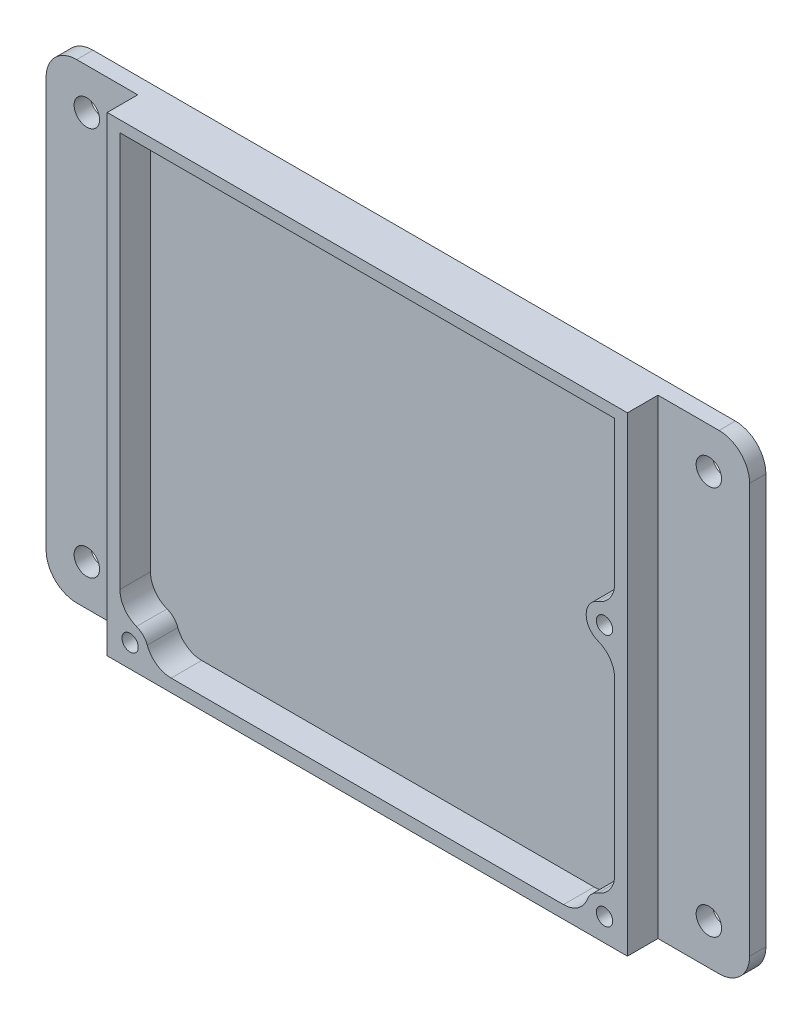
from build123d import *

# Parameters (mm, degrees)
SKETCH1_W           = 102.2
SKETCH1_H           = 92.45
SKETCH1_R           = 1.6
BOSS_EXTRUDE1_DEPTH = 6
SKETCH2_W           = 138.2
SKETCH2_H           = 92.45
SKETCH2_R           = 2.5
BOSS_EXTRUDE2_DEPTH = 3.2
FILLET1_R           = 6
FILLET2_R           = 5
FILLET3_R           = 5


with BuildPart() as part:
    # Sketch1 → Boss-Extrude1 (new body)
    with BuildSketch(Plane.XY):
        with Locations((51.1, 46.225)):
            Rectangle(SKETCH1_W, SKETCH1_H)
        with BuildLine():
            Line((94.706674091, 2.5), (7.493325909, 2.5))
            ThreePointArc((7.493325909, 2.5), (7.045584412, 7.045584412), (2.5, 7.493325909))
            Line((2.5, 7.493325909), (2.5, 90.25))
            Line((2.5, 90.25), (99.7, 90.25))
            Line((99.7, 90.25), (99.7, 57.093325909))
            ThreePointArc((99.7, 57.093325909), (94.1, 54.1), (99.7, 51.106674091))
            Line((99.7, 51.106674091), (99.7, 7.493325909))
            ThreePointArc((99.7, 7.493325909), (95.154415588, 7.045584412), (94.706674091, 2.5))
        make_face(mode=Mode.SUBTRACT)
        with Locations((4.5, 4.5)):
            Circle(SKETCH1_R, mode=Mode.SUBTRACT)
        with Locations((97.7, 4.5)):
            Circle(SKETCH1_R, mode=Mode.SUBTRACT)
        with Locations((97.7, 54.1)):
            Circle(SKETCH1_R, mode=Mode.SUBTRACT)
    extrude(amount=BOSS_EXTRUDE1_DEPTH)

    # Sketch2 → Boss-Extrude2 (add)
    with BuildSketch(Plane(origin=(0, 0, 0), x_dir=(-1, 0, 0), z_dir=(0, 0, -1))):
        with Locations((-51.1, 46.225)):
            Rectangle(SKETCH2_W, SKETCH2_H)
        with Locations((-112.2, 84.45)):
            Circle(SKETCH2_R, mode=Mode.SUBTRACT)
        with Locations((-112.2, 8)):
            Circle(SKETCH2_R, mode=Mode.SUBTRACT)
        with Locations((10, 8)):
            Circle(SKETCH2_R, mode=Mode.SUBTRACT)
        with Locations((10, 84.45)):
            Circle(SKETCH2_R, mode=Mode.SUBTRACT)
    extrude(amount=BOSS_EXTRUDE2_DEPTH)

    # Fillet1
    fillet1_edges = [part.edges().sort_by_distance(p)[0] for p in [
        (120.2, 92.45, -1.6),
        (120.2, 0, -1.6),
        (-18, 0, -1.6),
        (-18, 92.45, -1.6),
    ]]
    fillet(fillet1_edges, radius=FILLET1_R)

    # Fillet2
    fillet2_edges = [part.edges().sort_by_distance(p)[0] for p in [
        (99.7, 51.106674091, 3),
        (99.7, 57.093325909, 3),
    ]]
    fillet(fillet2_edges, radius=FILLET2_R)

    # Fillet3
    fillet3_edges = [part.edges().sort_by_distance(p)[0] for p in [
        (7.493325909, 2.5, 3),
        (94.706674091, 2.5, 3),
        (99.7, 7.493325909, 3),
        (2.5, 7.493325909, 3),
    ]]
    fillet(fillet3_edges, radius=FILLET3_R)


solid = part.part
